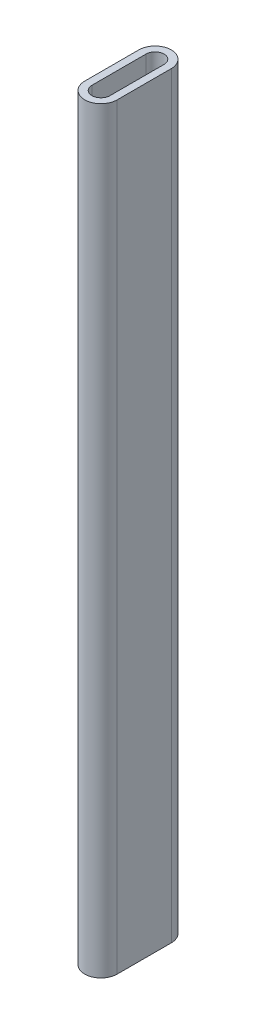
from build123d import *

# Parameters (mm, degrees)
BOSS_EXTRUDE1_DEPTH = 210


with BuildPart() as part:
    # Sketch2 → Boss-Extrude1 (new body)
    with BuildSketch(Plane(origin=(0, 0, 0), x_dir=(1, 0, 0), z_dir=(0, 1, 0))):
        with BuildLine():
            Line((-4.598436238, 8.02128028), (-4.598436238, -6.97871972))
            ThreePointArc((-4.598436238, -6.97871972), (-0.098436238, -11.47871972), (4.401563762, -6.97871972))
            Line((4.401563762, -6.97871972), (4.401563762, 8.02128028))
            ThreePointArc((4.401563762, 8.02128028), (-0.098436238, 12.52128028), (-4.598436238, 8.02128028))
        make_face()
        with BuildLine():
            Line((-2.598436238, 8.02128028), (-2.598436238, -6.97871972))
            ThreePointArc((-2.598436238, -6.97871972), (-0.098436238, -9.47871972), (2.401563762, -6.97871972))
            Line((2.401563762, -6.97871972), (2.401563762, 8.02128028))
            ThreePointArc((2.401563762, 8.02128028), (-0.098436238, 10.52128028), (-2.598436238, 8.02128028))
        make_face(mode=Mode.SUBTRACT)
    extrude(amount=BOSS_EXTRUDE1_DEPTH)


solid = part.part
